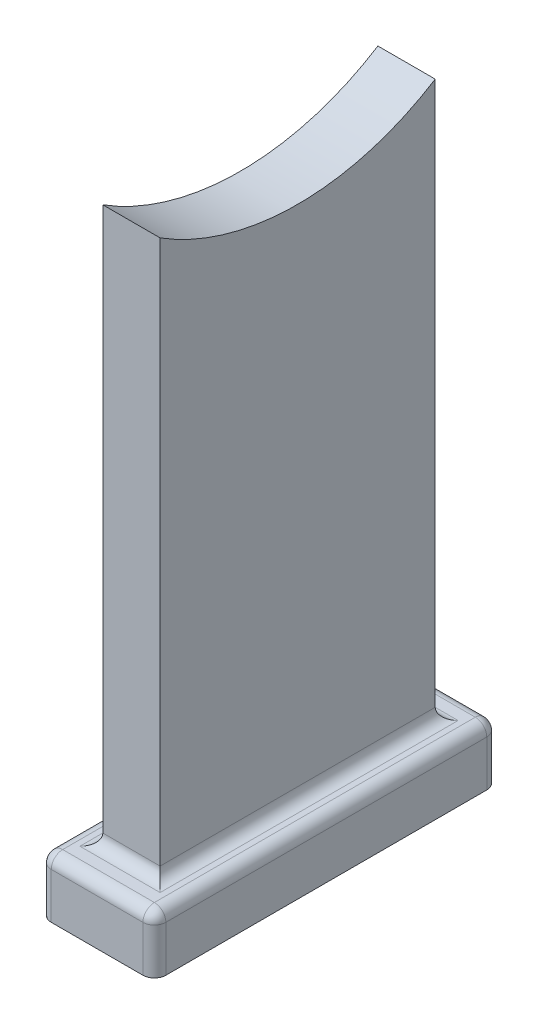
from build123d import *

# Parameters (mm, degrees)
SKETCH_1_W      = 20
SKETCH_1_H      = 60
EXTRUDE_1_DEPTH = 10
EXTRUDE_3_DEPTH = 5
FILLET_1_R      = 2


with BuildPart() as part:
    # 스케치1 → 보스-돌출1 (new body)
    with BuildSketch(Plane(origin=(0, 0, 0), x_dir=(1, 0, 0), z_dir=(0, 1, 0))):
        Rectangle(SKETCH_1_W, SKETCH_1_H)
    extrude(amount=EXTRUDE_1_DEPTH)

    # 스케치5 → 보스-돌출3 (add, symmetric)
    with BuildSketch(Plane(origin=(0, 0, 0), x_dir=(0, 0, -1), z_dir=(1, 0, 0))):
        with BuildLine():
            Line((-24, 0), (24, 0))
            Line((24, 0), (24, 100))
            Line((24, 100), (24, 106.934267379))
            ThreePointArc((24, 106.934267379), (0, 100), (-24, 106.934267379))
            Line((-24, 106.934267379), (-24, 100))
            Line((-24, 100), (-24, 0))
        make_face()
    extrude(amount=EXTRUDE_3_DEPTH, both=True)

    # 필렛1
    fillet_1_edges = [part.edges().sort_by_distance(p)[0] for p in [
        (10, 10, 0),
        (0, 10, -30),
        (0, 10, -24),
        (0, 10, 24),
        (-5, 10, 0),
        (5, 10, 0),
        (-10, 10, 0),
        (-10, 5, -30),
        (10, 5, -30),
        (10, 5, 30),
        (-10, 5, 30),
        (0, 10, 30),
    ]]
    fillet(fillet_1_edges, radius=FILLET_1_R)


solid = part.part
